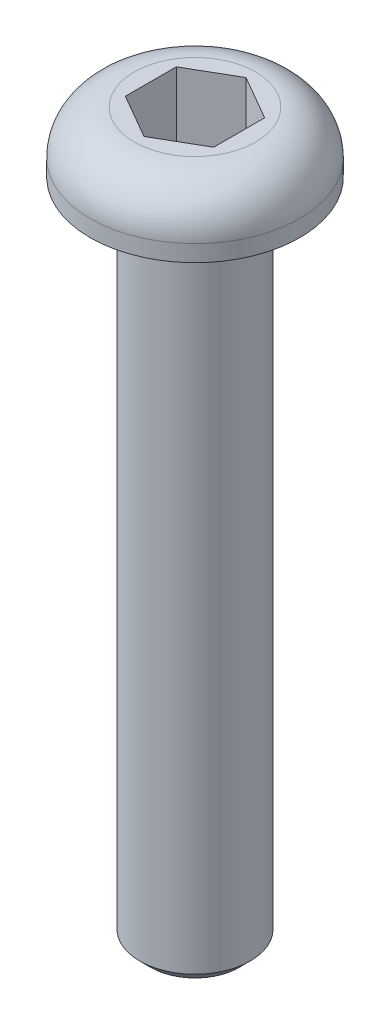
from build123d import *

# Parameters (mm, degrees)
CORTAR_EXTRUIR1_DEPTH = 3.5
CHAFL_N1_SIZE         = 0.5
REDONDEO1_R           = 2


with BuildPart() as part:
    # Croquis1 → Revolución1 (revolve)
    with BuildSketch(Plane.XY):
        Polygon((0, 0), (4.75, 0), (4.75, -2.75), (2.5, -2.75), (2.5, -32.75), (0, -32.75), align=None)
    revolve(axis=Axis((0, 0, 0), (0, -1, 0)))

    # Croquis2 → Cortar-Extruir1 (cut)
    with BuildSketch(Plane(origin=(0, 0, 0), x_dir=(1, 0, 0), z_dir=(0, 1, 0))):
        Polygon((2, 1.154700538), (0, 2.309401077), (-2, 1.154700538), (-2, -1.154700538), (0, -2.309401077), (2, -1.154700538), align=None)
    extrude(amount=-CORTAR_EXTRUIR1_DEPTH, mode=Mode.SUBTRACT)

    # Chaflán1
    chafl_n1_edges = [part.edges().sort_by_distance(p)[0] for p in [
        (-2.5, -32.75, 0),
    ]]
    chamfer(chafl_n1_edges, length=CHAFL_N1_SIZE)

    # Redondeo1
    redondeo1_edges = [part.edges().sort_by_distance(p)[0] for p in [
        (-4.75, 0, 0),
    ]]
    fillet(redondeo1_edges, radius=REDONDEO1_R)


solid = part.part
